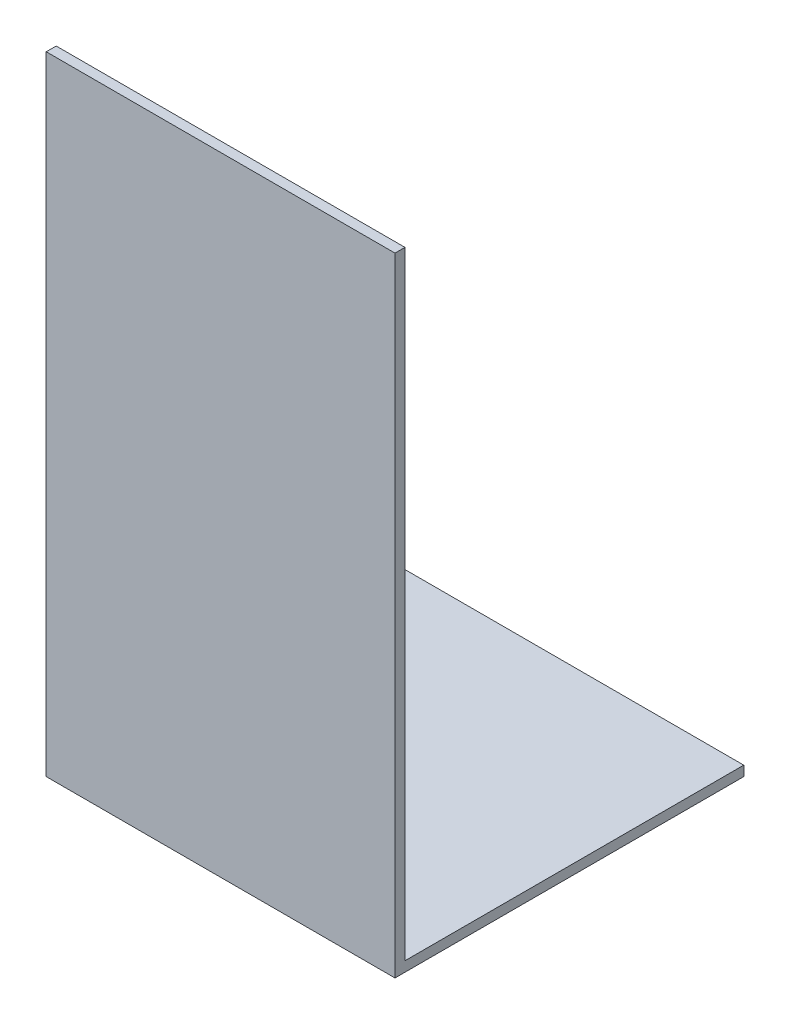
from build123d import *

# Parameters (mm, degrees)
SKETCH1_W           = 35
SKETCH1_H           = 35
BOSS_EXTRUDE1_DEPTH = 1
SKETCH2_W           = 35
SKETCH2_H           = 1
BOSS_EXTRUDE2_DEPTH = 62


with BuildPart() as part:
    # Sketch1 → Boss-Extrude1 (new body)
    with BuildSketch(Plane(origin=(0, 0, 0), x_dir=(1, 0, 0), z_dir=(0, 1, 0))):
        with Locations((17.5, 17.5)):
            Rectangle(SKETCH1_W, SKETCH1_H)
    extrude(amount=BOSS_EXTRUDE1_DEPTH)

    # Sketch2 → Boss-Extrude2 (add)
    with BuildSketch(Plane(origin=(0, 1, 0), x_dir=(1, 0, 0), z_dir=(0, 1, 0))):
        with Locations((17.5, 0.5)):
            Rectangle(SKETCH2_W, SKETCH2_H)
    extrude(amount=BOSS_EXTRUDE2_DEPTH)


solid = part.part
